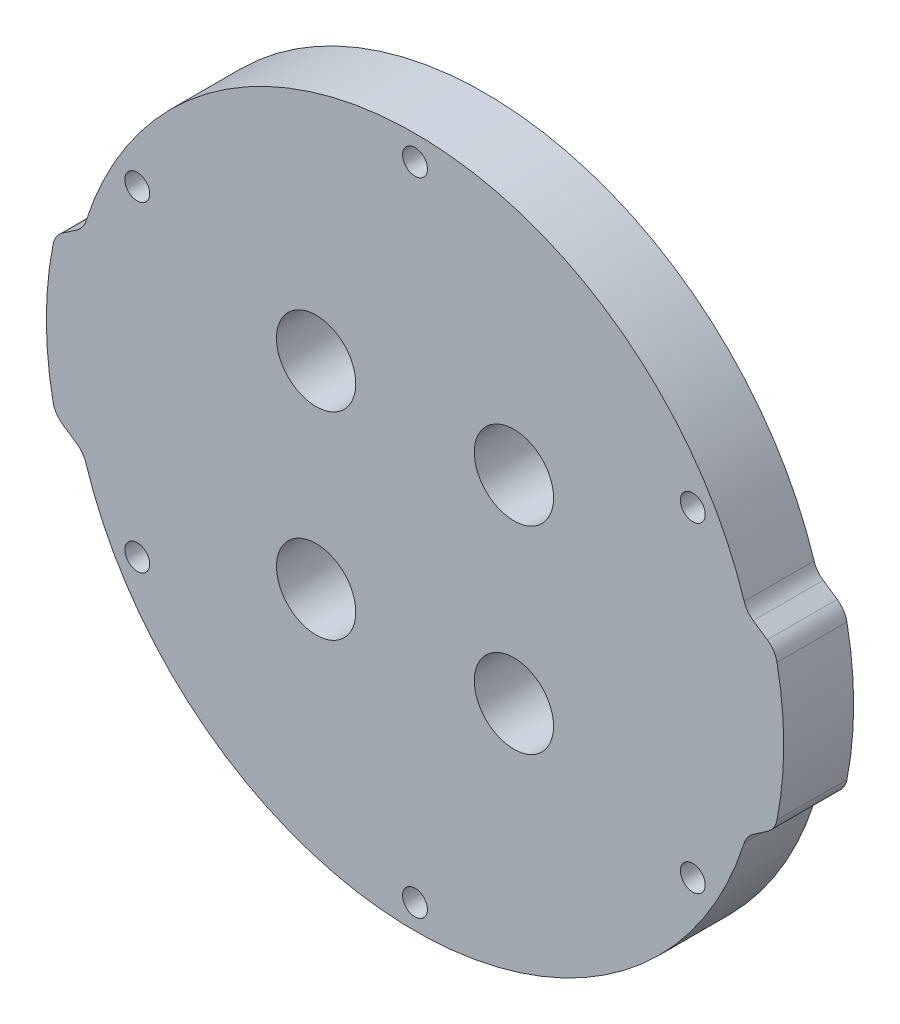
from build123d import *

# Parameters (mm, degrees)
SKETCH1_R           = 1.6
BOSS_EXTRUDE1_DEPTH = 9
FILLET1_R           = 3
SKETCH2_R           = 5.1
CUT_EXTRUDE1_DEPTH  = 10


with BuildPart() as part:
    # Sketch1 → Boss-Extrude1 (new body)
    with BuildSketch(Plane.XY):
        with BuildLine():
            Line((-46.324821937, 10), (-42.656212912, 12.5))
            ThreePointArc((-42.656212912, 12.5), (0, 44.45), (42.656212912, 12.5))
            Line((42.656212912, 12.5), (46.324821937, 10))
            ThreePointArc((46.324821937, 10), (47.45, 0), (46.324821937, -10))
            Line((46.324821937, -10), (42.656212912, -12.5))
            ThreePointArc((42.656212912, -12.5), (0, -44.45), (-42.656212912, -12.5))
            Line((-42.656212912, -12.5), (-46.324821937, -10))
            ThreePointArc((-46.324821937, -10), (-47.45, 0), (-46.324821937, 10))
        make_face()
        with Locations((0, 41.275)):
            Circle(SKETCH1_R, mode=Mode.SUBTRACT)
        with Locations((35.745198541, 20.6375)):
            Circle(SKETCH1_R, mode=Mode.SUBTRACT)
        with Locations((35.745198541, -20.6375)):
            Circle(SKETCH1_R, mode=Mode.SUBTRACT)
        with Locations((0, -41.275)):
            Circle(SKETCH1_R, mode=Mode.SUBTRACT)
        with Locations((-35.745198541, -20.6375)):
            Circle(SKETCH1_R, mode=Mode.SUBTRACT)
        with Locations((-35.745198541, 20.6375)):
            Circle(SKETCH1_R, mode=Mode.SUBTRACT)
    extrude(amount=BOSS_EXTRUDE1_DEPTH)

    # Fillet1
    fillet1_edges = [part.edges().sort_by_distance(p)[0] for p in [
        (46.324821937, -10, 4.5),
        (42.656212912, -12.5, 4.5),
        (-42.656212912, -12.5, 4.5),
        (-46.324821937, -10, 4.5),
        (-46.324821937, 10, 4.5),
        (-42.656212912, 12.5, 4.5),
        (42.656212912, 12.5, 4.5),
        (46.324821937, 10, 4.5),
    ]]
    fillet(fillet1_edges, radius=FILLET1_R)

    # Sketch2 → Cut-Extrude1 (cut, through all)
    with BuildSketch(Plane.XY.offset(9)):
        with Locations((12.727922061, 12.727922061)):
            Circle(SKETCH2_R)
        with Locations((12.727922061, -12.727922061)):
            Circle(SKETCH2_R)
        with Locations((-12.727922061, -12.727922061)):
            Circle(SKETCH2_R)
        with Locations((-12.727922061, 12.727922061)):
            Circle(SKETCH2_R)
    extrude(amount=-CUT_EXTRUDE1_DEPTH, mode=Mode.SUBTRACT)


solid = part.part
